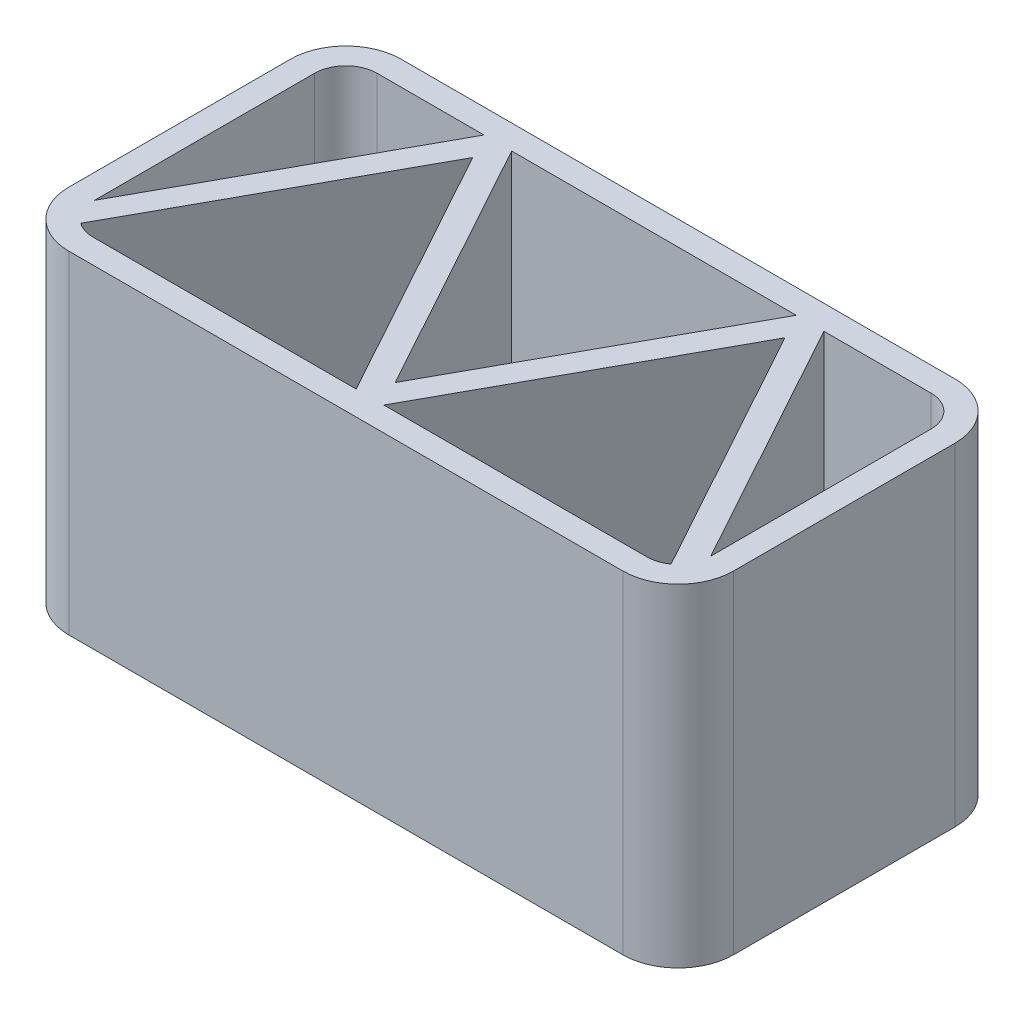
from build123d import *

# Parameters (mm, degrees)
EXTRUDE_THIN1_DEPTH = 304.8
EXTRUDE_THIN3_DEPTH = 304.8


with BuildPart() as part:
    # Sketch1 → Extrude-Thin1 (new body)
    with BuildSketch(Plane(origin=(0, 0, 0), x_dir=(1, 0, 0), z_dir=(0, 1, 0))):
        with BuildLine():
            Line((-254, 152.4), (254, 152.4))
            ThreePointArc((254, 152.4), (289.921024484, 137.521024484), (304.8, 101.6))
            Line((304.8, 101.6), (304.8, -101.6))
            ThreePointArc((304.8, -101.6), (289.921024484, -137.521024484), (254, -152.4))
            Line((254, -152.4), (-254, -152.4))
            ThreePointArc((-254, -152.4), (-289.921024484, -137.521024484), (-304.8, -101.6))
            Line((-304.8, -101.6), (-304.8, 101.6))
            ThreePointArc((-304.8, 101.6), (-289.921024484, 137.521024484), (-254, 152.4))
        make_face()
        with BuildLine():
            Line((-254, 130.175), (254, 130.175))
            ThreePointArc((254, 130.175), (274.205576272, 121.805576272), (282.575, 101.6))
            Line((282.575, 101.6), (282.575, -101.6))
            ThreePointArc((282.575, -101.6), (274.205576272, -121.805576272), (254, -130.175))
            Line((254, -130.175), (-254, -130.175))
            ThreePointArc((-254, -130.175), (-274.205576272, -121.805576272), (-282.575, -101.6))
            Line((-282.575, -101.6), (-282.575, 101.6))
            ThreePointArc((-282.575, 101.6), (-274.205576272, 121.805576272), (-254, 130.175))
        make_face(mode=Mode.SUBTRACT)
    extrude(amount=EXTRUDE_THIN1_DEPTH)

    # Sketch2 → Extrude-Thin3 (add)
    with BuildSketch(Plane(origin=(0, 304.8, 0), x_dir=(1, 0, 0), z_dir=(0, 1, 0))):
        with BuildLine():
            Line((-276.558924799, -135.529052432), (-143.148286149, 107.110665493))
            Line((-143.148286149, 107.110665493), (-11.963395498, -131.480987957))
            ThreePointArc((-11.963395498, -131.480987957), (0, -138.555652113), (11.963395498, -131.480987957))
            Line((11.963395498, -131.480987957), (143.148286149, 107.110665493))
            Line((143.148286149, 107.110665493), (276.558924799, -135.529052432))
            Line((276.558924799, -135.529052432), (296.034219796, -124.820947568))
            Line((296.034219796, -124.820947568), (155.111681647, 131.480987957))
            ThreePointArc((155.111681647, 131.480987957), (143.148286149, 138.555652113), (131.18489065, 131.480987957))
            Line((131.18489065, 131.480987957), (0, -107.110665493))
            Line((0, -107.110665493), (-131.18489065, 131.480987957))
            ThreePointArc((-131.18489065, 131.480987957), (-143.148286149, 138.555652113), (-155.111681647, 131.480987957))
            Line((-155.111681647, 131.480987957), (-296.034219796, -124.820947568))
            Line((-296.034219796, -124.820947568), (-276.558924799, -135.529052432))
        make_face()
    extrude(amount=-EXTRUDE_THIN3_DEPTH)


solid = part.part
